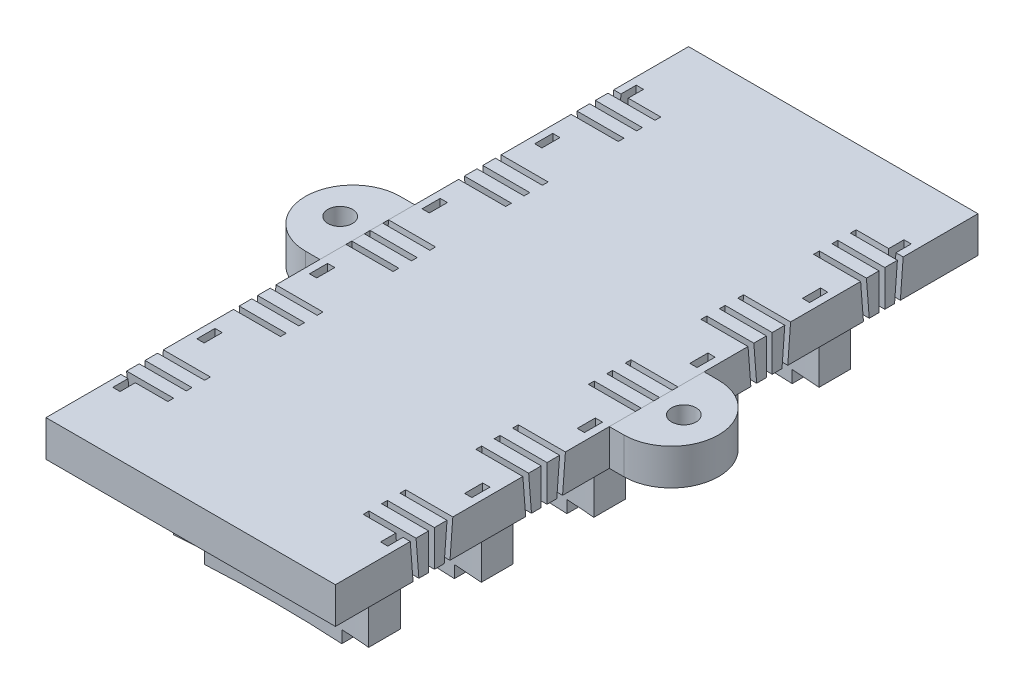
from build123d import *

# Parameters (mm, degrees)
SKETCH_2_W                           = 40
SKETCH_2_H                           = 88.8
EXTRUDE_1_DEPTH                      = 18
CUT_EXTRUDE_1_DEPTH                  = 13
EXTRUDE_2_DEPTH                      = 5
EXTRUDE_2_2_DEPTH                    = 5
SKETCH_11_W                          = 1.7
SKETCH_11_H                          = 5.001
HOLE_WIZARD_M31_AT_2_COUNT           = 2
HOLE_WIZARD_M31_AT_2_PITCH           = 47.5
SKETCH_18_W                          = 4.46
SKETCH_18_H                          = 13
CUT_EXTRUDE_5_DEPTH                  = 6.5
SKETCH_19_W                          = 0.8
SKETCH_19_H                          = 17
CUT_EXTRUDE_6_DEPTH                  = 6.5
PATTERN_LINEAR_9_COUNT               = 2
PATTERN_LINEAR_9_PITCH               = 15.56
PATTERN_LINEAR_9_COPY_1_SKETCH_W     = 4.46
PATTERN_LINEAR_9_COPY_1_SKETCH_H     = 13
PATTERN_LINEAR_9_COPY_1_DEPTH        = 6.5
PATTERN_LINEAR_9_COL_COUNT           = 4
PATTERN_LINEAR_9_COL_PITCH           = 15.56
PATTERN_LINEAR_9_COL_COPY_1_SKETCH_W = 4.46
PATTERN_LINEAR_9_COL_COPY_1_SKETCH_H = 13
PATTERN_LINEAR_9_COL_COPY_1_DEPTH    = 6.5
PATTERN_LINEAR_9_COL_COPY_2_SKETCH_W = 4.46
PATTERN_LINEAR_9_COL_COPY_2_SKETCH_H = 13
PATTERN_LINEAR_9_COL_COPY_2_DEPTH    = 6.5
PATTERN_LINEAR_9_COL_COPY_3_SKETCH_W = 4.46
PATTERN_LINEAR_9_COL_COPY_3_SKETCH_H = 13
PATTERN_LINEAR_9_COL_COPY_3_DEPTH    = 6.5
PATTERN_LINEAR_10_COUNT              = 5
PATTERN_LINEAR_10_PITCH              = 15.56
PATTERN_LINEAR_10_COPY_1_SKETCH_W    = 0.8
PATTERN_LINEAR_10_COPY_1_SKETCH_H    = 17
PATTERN_LINEAR_10_COPY_1_DEPTH       = 6.5
PATTERN_LINEAR_10_COPY_2_SKETCH_W    = 0.8
PATTERN_LINEAR_10_COPY_2_SKETCH_H    = 17
PATTERN_LINEAR_10_COPY_2_DEPTH       = 6.5
PATTERN_LINEAR_10_COPY_3_SKETCH_W    = 0.8
PATTERN_LINEAR_10_COPY_3_SKETCH_H    = 17
PATTERN_LINEAR_10_COPY_3_DEPTH       = 6.5
PATTERN_LINEAR_10_COPY_4_SKETCH_W    = 0.8
PATTERN_LINEAR_10_COPY_4_SKETCH_H    = 17
PATTERN_LINEAR_10_COPY_4_DEPTH       = 6.5
SKETCH_21_W                          = 1
SKETCH_21_H                          = 2.5
CUT_EXTRUDE_8_DEPTH                  = 5
SKETCH_22_W                          = 1
SKETCH_22_H                          = 2.5
CUT_EXTRUDE_9_DEPTH                  = 5
PATTERN_LINEAR_12_COUNT              = 4
PATTERN_LINEAR_12_PITCH              = 15.56
SKETCH_24_W                          = 4
SKETCH_24_H                          = 4.46
CUT_EXTRUDE_10_DEPTH                 = 1.7


with BuildPart() as part:
    # Эскиз2 → Бобышка-Вытянуть1 (new body)
    with BuildSketch(Plane(origin=(0, 0, 0), x_dir=(1, 0, 0), z_dir=(0, 1, 0))):
        Rectangle(SKETCH_2_W, SKETCH_2_H)
    extrude(amount=EXTRUDE_1_DEPTH)

    # Эскиз7 → Вырез-Вытянуть1 (cut)
    with BuildSketch(Plane.XZ):
        with BuildLine():
            Line((-20, 44.4), (20, 44.4))
            Line((20, 44.4), (20, 33.35))
            Line((20, 33.35), (14, 33.35))
            ThreePointArc((14, 33.35), (0, 32.75), (-14, 33.35))
            Line((-14, 33.35), (-20, 33.35))
            Line((-20, 33.35), (-20, 44.4))
        make_face()
        with BuildLine():
            Line((-20, 28.89), (-20, 17.79))
            Line((-20, 17.79), (-14, 17.79))
            ThreePointArc((-14, 17.79), (0, 17.19), (14, 17.79))
            Line((14, 17.79), (20, 17.79))
            Line((20, 17.79), (20, 28.89))
            Line((20, 28.89), (14, 28.89))
            ThreePointArc((14, 28.89), (0, 29.49), (-14, 28.89))
            Line((-14, 28.89), (-20, 28.89))
        make_face()
        with BuildLine():
            Line((-20, 13.33), (-20, 2.23))
            Line((-20, 2.23), (-14, 2.23))
            ThreePointArc((-14, 2.23), (0, 1.63), (14, 2.23))
            Line((14, 2.23), (20, 2.23))
            Line((20, 2.23), (20, 13.33))
            Line((20, 13.33), (14, 13.33))
            ThreePointArc((14, 13.33), (0, 13.93), (-14, 13.33))
            Line((-14, 13.33), (-20, 13.33))
        make_face()
        with BuildLine():
            Line((-20, -2.23), (-20, -13.33))
            Line((-20, -13.33), (-14, -13.33))
            ThreePointArc((-14, -13.33), (0, -13.93), (14, -13.33))
            Line((14, -13.33), (20, -13.33))
            Line((20, -13.33), (20, -2.23))
            Line((20, -2.23), (14, -2.23))
            ThreePointArc((14, -2.23), (0, -1.63), (-14, -2.23))
            Line((-14, -2.23), (-20, -2.23))
        make_face()
        with BuildLine():
            Line((-20, -33.35), (-20, -44.4))
            Line((-20, -44.4), (20, -44.4))
            Line((20, -44.4), (20, -33.35))
            Line((20, -33.35), (14, -33.35))
            ThreePointArc((14, -33.35), (0, -32.75), (-14, -33.35))
            Line((-14, -33.35), (-20, -33.35))
        make_face()
        with BuildLine():
            Line((-20, -17.79), (-20, -28.89))
            Line((-20, -28.89), (-14, -28.89))
            ThreePointArc((-14, -28.89), (0, -29.49), (14, -28.89))
            Line((14, -28.89), (20, -28.89))
            Line((20, -28.89), (20, -17.79))
            Line((20, -17.79), (14, -17.79))
            ThreePointArc((14, -17.79), (0, -17.19), (-14, -17.79))
            Line((-14, -17.79), (-20, -17.79))
        make_face()
    extrude(amount=-CUT_EXTRUDE_1_DEPTH, mode=Mode.SUBTRACT)

    # Эскиз18 → Вырез-Вытянуть5 (cut)
    with BuildSketch(Plane(origin=(20, 0, 0), x_dir=(0, 0, -1), z_dir=(1, 0, 0))):
        with Locations((-15.56, 6.5)):
            Rectangle(SKETCH_18_W, SKETCH_18_H)
    cut_extrude_5 = extrude(amount=-CUT_EXTRUDE_5_DEPTH, mode=Mode.SUBTRACT)

    # Эскиз19 → Вырез-Вытянуть6 (cut)
    with BuildSketch(Plane(origin=(20, 0, 0), x_dir=(0, 0, -1), z_dir=(1, 0, 0))):
        with Locations((-31.12, 9.5)):
            Rectangle(SKETCH_19_W, SKETCH_19_H)
        Polygon((-34.06, 18), (-33.26, 18), (-32.87, 13), (-33.67, 13), align=None)
        Polygon((-28.98, 18), (-28.18, 18), (-28.57, 13), (-29.37, 13), align=None)
    cut_extrude_6 = extrude(amount=-CUT_EXTRUDE_6_DEPTH, mode=Mode.SUBTRACT)

    # Зеркальное отражение5: Вырез-Вытянуть6 across plane
    add(cut_extrude_6.mirror(Plane(origin=(0, 0, 0), x_dir=(0, 0, 1), z_dir=(1, 0, 0))), mode=Mode.SUBTRACT)

    # Зеркальное отражение6: Вырез-Вытянуть5 across plane
    add(cut_extrude_5.mirror(Plane(origin=(0, 0, 0), x_dir=(0, 0, 1), z_dir=(1, 0, 0))), mode=Mode.SUBTRACT)

    # Линейный массив9: Вырез-Вытянуть5 ×2
    with Locations(*[(0, 0, i * PATTERN_LINEAR_9_PITCH) for i in range(1, PATTERN_LINEAR_9_COUNT)]):
        add(cut_extrude_5, mode=Mode.SUBTRACT)

    # Линейный массив9 copy 1 sketch → Линейный массив9 copy 1 (cut)
    with BuildSketch(Plane(origin=(-20, 0, 15.56), x_dir=(0, 0, -1), z_dir=(-1, 0, 0))):
        with Locations((-15.56, -6.5)):
            Rectangle(PATTERN_LINEAR_9_COPY_1_SKETCH_W, PATTERN_LINEAR_9_COPY_1_SKETCH_H)
    extrude(amount=-PATTERN_LINEAR_9_COPY_1_DEPTH, mode=Mode.SUBTRACT)

    # Линейный массив9 col: Вырез-Вытянуть5 ×4
    with Locations(*[(0, 0, -i * PATTERN_LINEAR_9_COL_PITCH) for i in range(1, PATTERN_LINEAR_9_COL_COUNT)]):
        add(cut_extrude_5, mode=Mode.SUBTRACT)

    # Линейный массив9 col copy 1 sketch → Линейный массив9 col copy 1 (cut)
    with BuildSketch(Plane(origin=(-20, 0, -15.56), x_dir=(0, 0, -1), z_dir=(-1, 0, 0))):
        with Locations((-15.56, -6.5)):
            Rectangle(PATTERN_LINEAR_9_COL_COPY_1_SKETCH_W, PATTERN_LINEAR_9_COL_COPY_1_SKETCH_H)
    extrude(amount=-PATTERN_LINEAR_9_COL_COPY_1_DEPTH, mode=Mode.SUBTRACT)

    # Линейный массив9 col copy 2 sketch → Линейный массив9 col copy 2 (cut)
    with BuildSketch(Plane(origin=(-20, 0, -31.12), x_dir=(0, 0, -1), z_dir=(-1, 0, 0))):
        with Locations((-15.56, -6.5)):
            Rectangle(PATTERN_LINEAR_9_COL_COPY_2_SKETCH_W, PATTERN_LINEAR_9_COL_COPY_2_SKETCH_H)
    extrude(amount=-PATTERN_LINEAR_9_COL_COPY_2_DEPTH, mode=Mode.SUBTRACT)

    # Линейный массив9 col copy 3 sketch → Линейный массив9 col copy 3 (cut)
    with BuildSketch(Plane(origin=(-20, 0, -46.68), x_dir=(0, 0, -1), z_dir=(-1, 0, 0))):
        with Locations((-15.56, -6.5)):
            Rectangle(PATTERN_LINEAR_9_COL_COPY_3_SKETCH_W, PATTERN_LINEAR_9_COL_COPY_3_SKETCH_H)
    extrude(amount=-PATTERN_LINEAR_9_COL_COPY_3_DEPTH, mode=Mode.SUBTRACT)

    # Линейный массив10: Вырез-Вытянуть6 ×5
    with Locations(*[(0, 0, -i * PATTERN_LINEAR_10_PITCH) for i in range(1, PATTERN_LINEAR_10_COUNT)]):
        add(cut_extrude_6, mode=Mode.SUBTRACT)

    # Линейный массив10 copy 1 sketch → Линейный массив10 copy 1 (cut)
    with BuildSketch(Plane(origin=(-20, 0, -15.56), x_dir=(0, 0, -1), z_dir=(-1, 0, 0))):
        with Locations((-31.12, -9.5)):
            Rectangle(PATTERN_LINEAR_10_COPY_1_SKETCH_W, PATTERN_LINEAR_10_COPY_1_SKETCH_H)
        Polygon((-34.06, -18), (-33.26, -18), (-32.87, -13), (-33.67, -13), align=None)
        Polygon((-28.98, -18), (-28.18, -18), (-28.57, -13), (-29.37, -13), align=None)
    extrude(amount=-PATTERN_LINEAR_10_COPY_1_DEPTH, mode=Mode.SUBTRACT)

    # Линейный массив10 copy 2 sketch → Линейный массив10 copy 2 (cut)
    with BuildSketch(Plane(origin=(-20, 0, -31.12), x_dir=(0, 0, -1), z_dir=(-1, 0, 0))):
        with Locations((-31.12, -9.5)):
            Rectangle(PATTERN_LINEAR_10_COPY_2_SKETCH_W, PATTERN_LINEAR_10_COPY_2_SKETCH_H)
        Polygon((-34.06, -18), (-33.26, -18), (-32.87, -13), (-33.67, -13), align=None)
        Polygon((-28.98, -18), (-28.18, -18), (-28.57, -13), (-29.37, -13), align=None)
    extrude(amount=-PATTERN_LINEAR_10_COPY_2_DEPTH, mode=Mode.SUBTRACT)

    # Линейный массив10 copy 3 sketch → Линейный массив10 copy 3 (cut)
    with BuildSketch(Plane(origin=(-20, 0, -46.68), x_dir=(0, 0, -1), z_dir=(-1, 0, 0))):
        with Locations((-31.12, -9.5)):
            Rectangle(PATTERN_LINEAR_10_COPY_3_SKETCH_W, PATTERN_LINEAR_10_COPY_3_SKETCH_H)
        Polygon((-34.06, -18), (-33.26, -18), (-32.87, -13), (-33.67, -13), align=None)
        Polygon((-28.98, -18), (-28.18, -18), (-28.57, -13), (-29.37, -13), align=None)
    extrude(amount=-PATTERN_LINEAR_10_COPY_3_DEPTH, mode=Mode.SUBTRACT)

    # Линейный массив10 copy 4 sketch → Линейный массив10 copy 4 (cut)
    with BuildSketch(Plane(origin=(-20, 0, -62.24), x_dir=(0, 0, -1), z_dir=(-1, 0, 0))):
        with Locations((-31.12, -9.5)):
            Rectangle(PATTERN_LINEAR_10_COPY_4_SKETCH_W, PATTERN_LINEAR_10_COPY_4_SKETCH_H)
        Polygon((-34.06, -18), (-33.26, -18), (-32.87, -13), (-33.67, -13), align=None)
        Polygon((-28.98, -18), (-28.18, -18), (-28.57, -13), (-29.37, -13), align=None)
    extrude(amount=-PATTERN_LINEAR_10_COPY_4_DEPTH, mode=Mode.SUBTRACT)

    # Эскиз21 → Вырез-Вытянуть8 (cut)
    with BuildSketch(Plane.XZ.offset(-13)):
        with Locations((18.5, -34.92)):
            Rectangle(SKETCH_21_W, SKETCH_21_H)
        with Locations((-18.5, -34.92)):
            Rectangle(SKETCH_21_W, SKETCH_21_H)
    cut_extrude_8 = extrude(amount=-CUT_EXTRUDE_8_DEPTH, mode=Mode.SUBTRACT)

    # Зеркальное отражение7: Вырез-Вытянуть8 across plane
    add(cut_extrude_8.mirror(Plane.XY), mode=Mode.SUBTRACT)

    # Эскиз22 → Вырез-Вытянуть9 (cut)
    with BuildSketch(Plane.XZ.offset(-13)):
        with Locations((-18.5, -23.382163838)):
            Rectangle(SKETCH_22_W, SKETCH_22_H)
        with Locations((18.5, -23.382163838)):
            Rectangle(SKETCH_22_W, SKETCH_22_H)
    cut_extrude_9 = extrude(amount=-CUT_EXTRUDE_9_DEPTH, mode=Mode.SUBTRACT)

    # Линейный массив12: Вырез-Вытянуть9 ×4
    with Locations(*[(0, 0, i * PATTERN_LINEAR_12_PITCH) for i in range(1, PATTERN_LINEAR_12_COUNT)]):
        add(cut_extrude_9, mode=Mode.SUBTRACT)

    # Эскиз24 → Вырез-Вытянуть10 (cut)
    with BuildSketch(Plane.XZ):
        with Locations((-11.5, 31.12)):
            Rectangle(SKETCH_24_W, SKETCH_24_H)
        with Locations((11.5, 31.12)):
            Rectangle(SKETCH_24_W, SKETCH_24_H)
        with Locations((11.5, 15.56)):
            Rectangle(SKETCH_24_W, SKETCH_24_H)
        with Locations((11.5, 0)):
            Rectangle(SKETCH_24_W, SKETCH_24_H)
        with Locations((11.5, -15.56)):
            Rectangle(SKETCH_24_W, SKETCH_24_H)
        with Locations((11.5, -31.12)):
            Rectangle(SKETCH_24_W, SKETCH_24_H)
        with Locations((-11.5, 15.56)):
            Rectangle(SKETCH_24_W, SKETCH_24_H)
        with Locations((-11.5, 0)):
            Rectangle(SKETCH_24_W, SKETCH_24_H)
        with Locations((-11.5, -15.56)):
            Rectangle(SKETCH_24_W, SKETCH_24_H)
        with Locations((-11.5, -31.12)):
            Rectangle(SKETCH_24_W, SKETCH_24_H)
    extrude(amount=-CUT_EXTRUDE_10_DEPTH, mode=Mode.SUBTRACT)


with BuildPart() as body_2:
    # Эскиз3 → Бобышка-Вытянуть2 (new body)
    with BuildSketch(Plane(origin=(0, 13, 0), x_dir=(1, 0, 0), z_dir=(0, 1, 0))):
        with BuildLine():
            Line((-22, 6.55), (-20, 6.55))
            Line((-20, 6.55), (-20, -6.55))
            Line((-20, -6.55), (-22, -6.55))
            ThreePointArc((-22, -6.55), (-28.55, 0), (-22, 6.55))
        make_face()
    extrude(amount=EXTRUDE_2_DEPTH)


with BuildPart() as body_3:
    # Эскиз3 → Extrude 2 2 (new body)
    with BuildSketch(Plane(origin=(0, 13, 0), x_dir=(1, 0, 0), z_dir=(0, 1, 0))):
        with BuildLine():
            Line((22, 6.55), (20, 6.55))
            Line((20, 6.55), (20, -6.55))
            Line((20, -6.55), (22, -6.55))
            ThreePointArc((22, -6.55), (28.55, 0), (22, 6.55))
        make_face()
    extrude(amount=EXTRUDE_2_2_DEPTH)

    # Эскиз11 → Отверстие с зазором M31 (revolve, cut)
    with BuildSketch(Plane(origin=(23.75, 13, 0), x_dir=(0, 0, -1), z_dir=(1, 0, 0))):
        with Locations((0.85, 2.5005)):
            Rectangle(SKETCH_11_W, SKETCH_11_H)
    hole_wizard_m31 = revolve(axis=Axis((23.75, 6.65, 0), (0, 1, 0)), mode=Mode.SUBTRACT)


with BuildPart() as body_2_1:
    add(body_2.part)

    # Отверстие с зазором M31 at 2: Отверстие с зазором M31 ×2
    with Locations(*[(-i * HOLE_WIZARD_M31_AT_2_PITCH, 0, 0) for i in range(1, HOLE_WIZARD_M31_AT_2_COUNT)]):
        add(hole_wizard_m31, mode=Mode.SUBTRACT)


solid = Compound([part.part, body_3.part, body_2_1.part])
